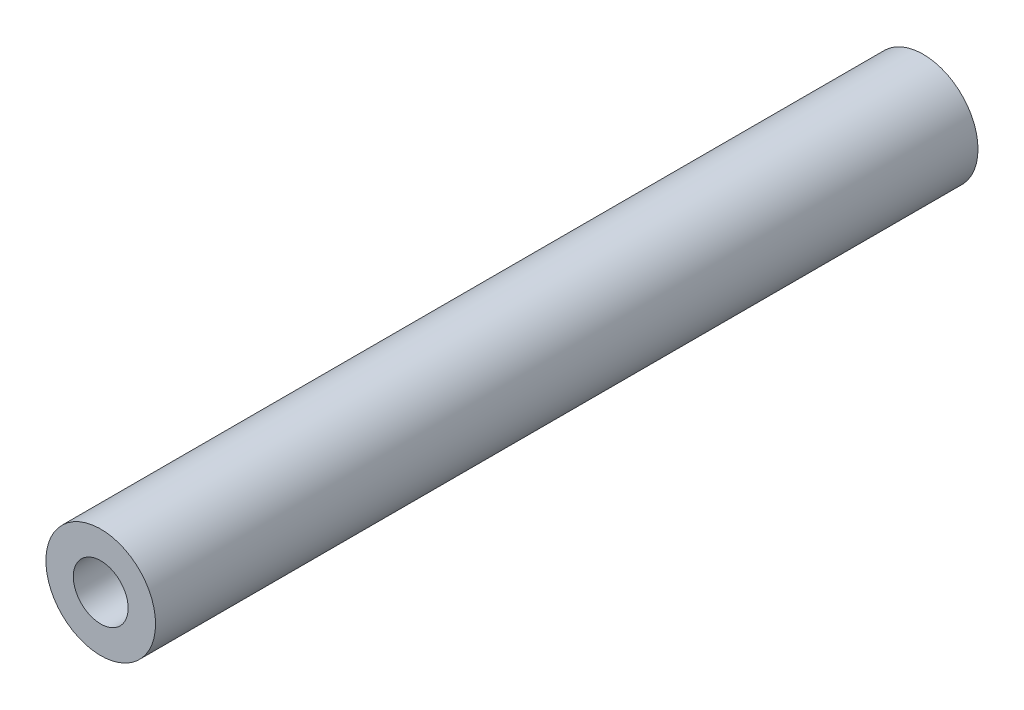
from build123d import *

# Parameters (mm, degrees)
SKETCH_1_R      = 3
SKETCH_1_R_2    = 1.5
EXTRUDE_1_DEPTH = 22.5


with BuildPart() as part:
    # 草图1 → 凸台-拉伸1 (new body, symmetric)
    with BuildSketch(Plane.XY):
        Circle(SKETCH_1_R)
        Circle(SKETCH_1_R_2, mode=Mode.SUBTRACT)
    extrude(amount=EXTRUDE_1_DEPTH, both=True)


solid = part.part
